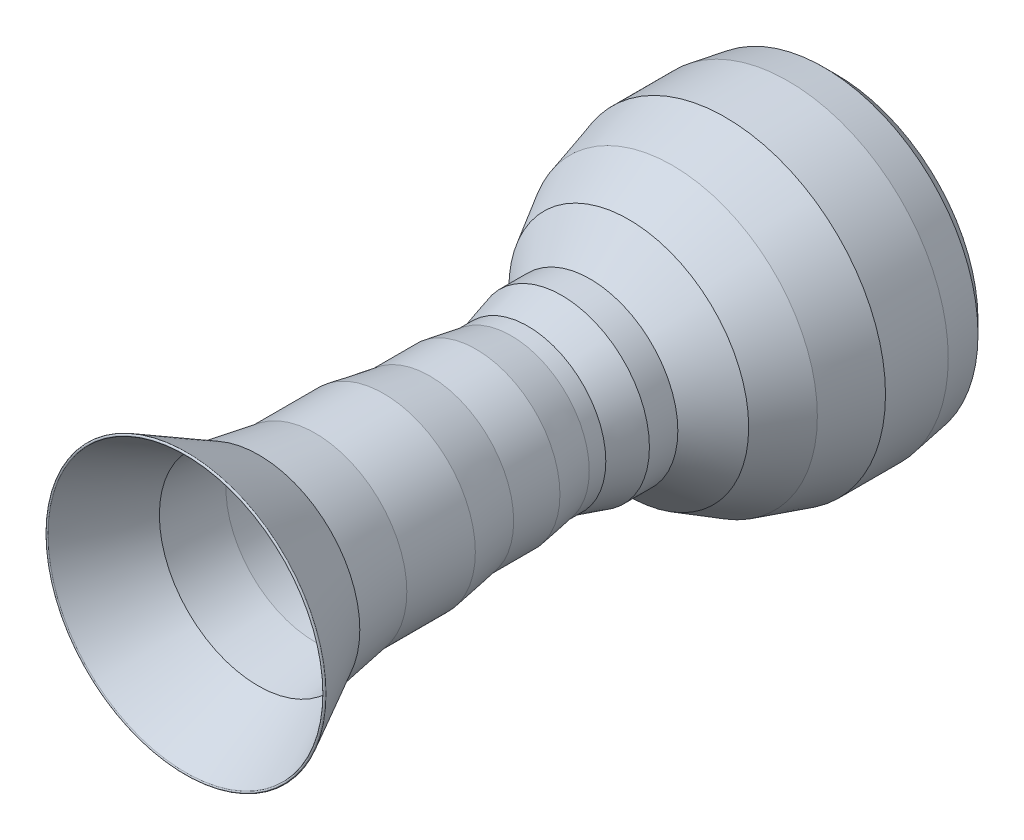
from build123d import *


with BuildPart() as part:
    # Sketch4 → Revolve4 (revolve)
    with BuildSketch(Plane(origin=(0, 0, 0), x_dir=(0, 0, -1), z_dir=(1, 0, 0))):
        with BuildLine():
            Line((1240.300507045, 594.53880855), (1554.39522647, 427.217322501))
            Line((1554.39522647, 427.217322501), (1800.974258542, 386.120817156))
            Line((1800.974258542, 386.120817156), (2097.456189961, 386.120817156))
            Line((2097.456189961, 386.120817156), (2296.433092289, 352.958000101))
            Line((2296.433092289, 352.958000101), (2496.679384744, 352.958000101))
            Line((2496.679384744, 352.958000101), (2648.864680078, 327.593784212))
            Line((2648.864680078, 327.593784212), (2722.710164143, 327.593784212))
            Line((2722.710164143, 327.593784212), (2869.483397519, 369.539408628))
            Line((2869.483397519, 369.539408628), (2981.031054885, 369.539408628))
            Line((2981.031054885, 369.539408628), (2981.031054885, 327.593784212))
            Line((2981.031054885, 327.593784212), (3164.315336198, 510.878065525))
            Line((3164.315336198, 510.878065525), (3350.899602992, 618.02252589))
            Line((3350.899602992, 618.02252589), (3577.701714063, 682.839222702))
            Line((3577.701714063, 682.839222702), (3846.993131803, 682.839222702))
            Line((3846.993131803, 682.839222702), (3997.454208948, 657.762376511))
            Line((3997.454208948, 657.762376511), (4049.238056051, 605.978529409))
            ThreePointArc((4049.238056051, 605.978529409), (4056.309123863, 605.978529409), (4056.309123863, 613.04959722))
            Line((4056.309123863, 613.04959722), (4002.259246636, 667.099474447))
            Line((4002.259246636, 667.099474447), (3847.820757106, 692.839222702))
            Line((3847.820757106, 692.839222702), (3576.30083017, 692.839222702))
            Line((3576.30083017, 692.839222702), (3346.978241691, 627.302210637))
            Line((3346.978241691, 627.302210637), (3158.183590503, 518.888455454))
            Line((3158.183590503, 518.888455454), (2991.031054885, 351.735919836))
            Line((2991.031054885, 351.735919836), (2991.031054885, 379.539408628))
            Line((2991.031054885, 379.539408628), (2868.082513625, 379.539408628))
            Line((2868.082513625, 379.539408628), (2721.309280249, 337.593784212))
            Line((2721.309280249, 337.593784212), (2649.692305381, 337.593784212))
            Line((2649.692305381, 337.593784212), (2497.507010047, 362.958000101))
            Line((2497.507010047, 362.958000101), (2297.260717592, 362.958000101))
            Line((2297.260717592, 362.958000101), (2098.283815264, 396.120817156))
            Line((2098.283815264, 396.120817156), (1801.801883845, 396.120817156))
            Line((1801.801883845, 396.120817156), (1557.652939644, 436.812307856))
            Line((1557.652939644, 436.812307856), (1245.002107656, 603.364620223))
            ThreePointArc((1245.002107656, 603.364620223), (1238.238401514, 601.302514692), (1240.300507045, 594.53880855))
        make_face()
    revolve(axis=Axis((0, 0, 0), (0, 0, -1)))


solid = part.part
